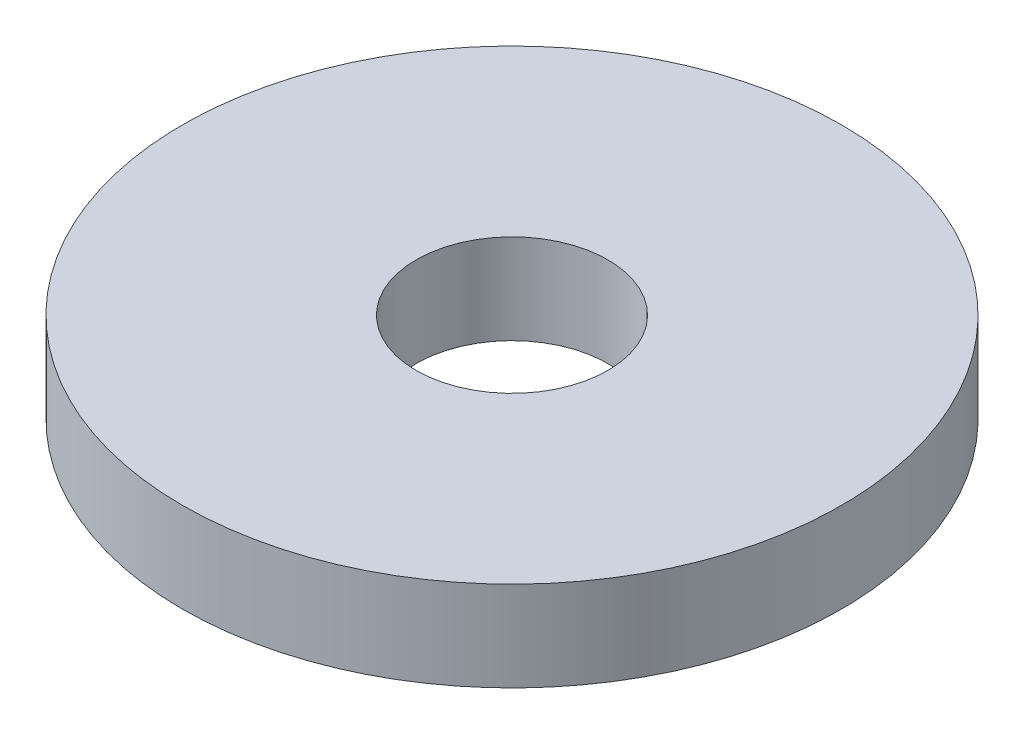
from build123d import *

# Parameters (mm, degrees)
CROQUIS1_R              = 11
CROQUIS1_R_2            = 3.2
SALIENTE_EXTRUIR1_DEPTH = 3


with BuildPart() as part:
    # Croquis1 → Saliente-Extruir1 (new body)
    with BuildSketch(Plane(origin=(0, 0, 0), x_dir=(1, 0, 0), z_dir=(0, 1, 0))):
        Circle(CROQUIS1_R)
        Circle(CROQUIS1_R_2, mode=Mode.SUBTRACT)
    extrude(amount=SALIENTE_EXTRUIR1_DEPTH)


solid = part.part
